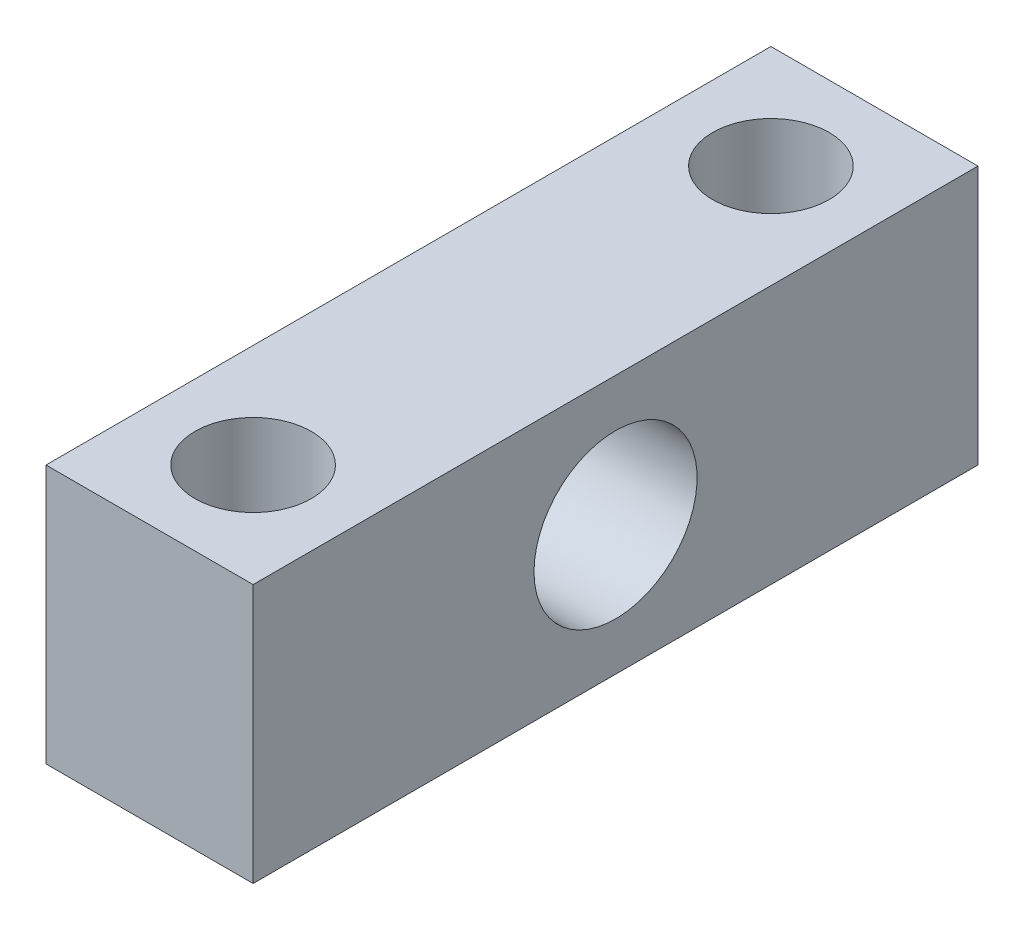
from build123d import *

# Parameters (mm, degrees)
ESQUISSE1_W                  = 8
ESQUISSE1_H                  = 10
BOSS_EXTRU_1_DEPTH           = 28
ESQUISSE2_R                  = 2.25
ENL_V_MAT_EXTRU_1_DEPTH      = 11
ESQUISSE3_R                  = 3.15
ENL_V_MAT_EXTRU_2_DEPTH      = 1
ENL_V_MAT_EXTRU_2_DEPTH_BACK = 9
ESQUISSE4_R                  = 3.65
ENL_V_MAT_EXTRU_3_DEPTH      = 1


with BuildPart() as part:
    # Esquisse1 → Boss.-Extru.1 (new body)
    with BuildSketch(Plane.XY):
        with Locations((4, 5)):
            Rectangle(ESQUISSE1_W, ESQUISSE1_H)
    extrude(amount=BOSS_EXTRU_1_DEPTH)

    # Esquisse2 → Enlèv. mat.-Extru.1 (cut, through all)
    with BuildSketch(Plane(origin=(0, 10, 0), x_dir=(1, 0, 0), z_dir=(0, 1, 0))):
        with Locations((4, -24)):
            Circle(ESQUISSE2_R)
        with Locations((4, -4)):
            Circle(ESQUISSE2_R)
    extrude(amount=-ENL_V_MAT_EXTRU_1_DEPTH, mode=Mode.SUBTRACT)

    # Esquisse3 → Enlèv. mat.-Extru.2 (cut, two sides)
    with BuildSketch(Plane.ZY) as enl_v_mat_extru_2_sk:
        with Locations((14, 5)):
            Circle(ESQUISSE3_R)
    extrude(amount=ENL_V_MAT_EXTRU_2_DEPTH, mode=Mode.SUBTRACT)
    extrude(enl_v_mat_extru_2_sk.sketch, amount=-ENL_V_MAT_EXTRU_2_DEPTH_BACK, mode=Mode.SUBTRACT)

    # Esquisse4 → Enlèv. mat.-Extru.3 (cut)
    with BuildSketch(Plane.ZY):
        with Locations((14, 5)):
            Circle(ESQUISSE4_R)
    extrude(amount=-ENL_V_MAT_EXTRU_3_DEPTH, mode=Mode.SUBTRACT)


solid = part.part
